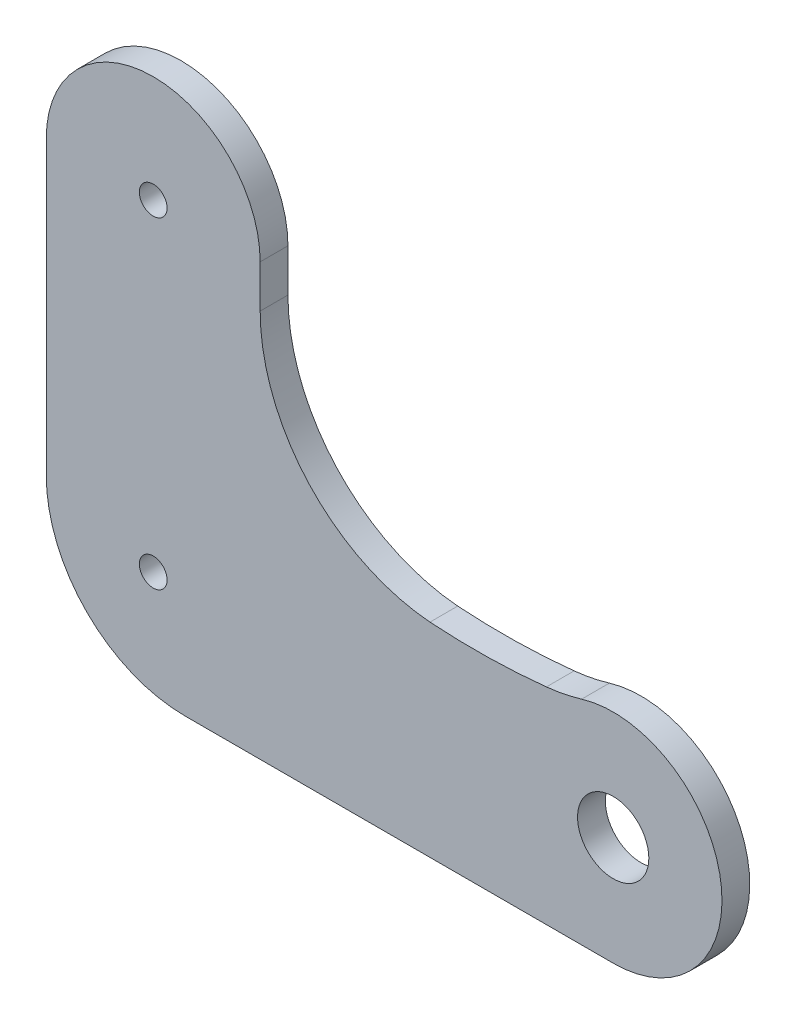
from build123d import *

# Parameters (mm, degrees)
SKETCH_1_R      = 1.5
SKETCH_1_R_2    = 3.85
EXTRUDE_1_DEPTH = 3


with BuildPart() as part:
    # 草圖1 → 填料-伸長1 (new body)
    with BuildSketch(Plane.XY):
        with BuildLine():
            Line((-1.088072116, -16.755807147), (45.162709199, -16.755807147))
            ThreePointArc((45.162709199, -16.755807147), (56.790010388, -3.27850574), (41.753879517, 6.247592861))
            ThreePointArc((41.753879517, 6.247592861), (39.868271169, 5.774911831), (37.945680681, 5.487523562))
            ThreePointArc((37.945680681, 5.487523562), (31.659768337, 5.100288193), (25.363940234, 5.25901355))
            ThreePointArc((25.363940234, 5.25901355), (12.306009375, 11.647221283), (7.023040081, 25.190078877))
            Line((7.023040081, 25.190078877), (7.023039951, 29.795438865))
            ThreePointArc((7.023039951, 29.795438865), (-4.532515913, 41.350994164), (-16.088071721, 29.795438809))
            Line((-16.088071721, 29.795438809), (-16.088072116, 20.328730687))
            Line((-16.088072116, 20.328730687), (-16.088072116, -1.755807147))
            ThreePointArc((-16.088072116, -1.755807147), (-11.694673834, -12.362408864), (-1.088072116, -16.755807147))
        make_face()
        with Locations((-4.532515885, 29.795438328)):
            Circle(SKETCH_1_R, mode=Mode.SUBTRACT)
        with Locations((45.162709199, -5.00153318)):
            Circle(SKETCH_1_R_2, mode=Mode.SUBTRACT)
        with Locations((-4.532515885, -5.00153318)):
            Circle(SKETCH_1_R, mode=Mode.SUBTRACT)
    extrude(amount=EXTRUDE_1_DEPTH)


solid = part.part
